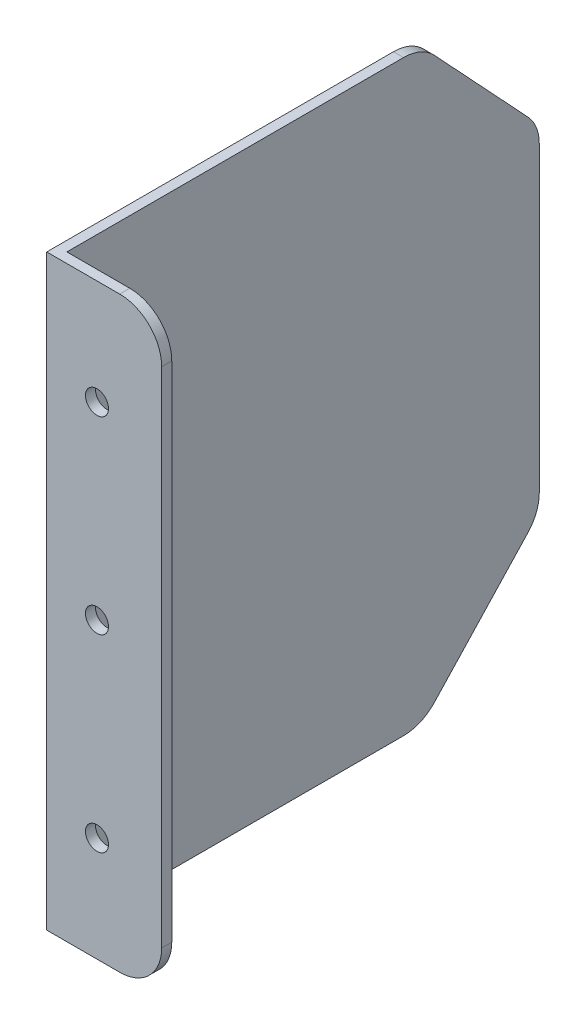
from build123d import *

# Parameters (mm, degrees)
SKETCH1_W           = 115
SKETCH1_H           = 140
BOSS_EXTRUDE1_DEPTH = 2.4
CUT_EXTRUDE1_DEPTH  = 3.4
FILLET1_R           = 10
SKETCH3_W           = 2.4
SKETCH3_H           = 140
BOSS_EXTRUDE2_DEPTH = 25
FILLET2_R           = 10
SKETCH4_R           = 2.75
CUT_EXTRUDE2_DEPTH  = 116


with BuildPart() as part:
    # Sketch1 → Boss-Extrude1 (new body)
    with BuildSketch(Plane(origin=(0, 0, 0), x_dir=(0, 0, -1), z_dir=(1, 0, 0))):
        with Locations((57.5, -70)):
            Rectangle(SKETCH1_W, SKETCH1_H)
    extrude(amount=BOSS_EXTRUDE1_DEPTH)

    # Sketch2 → Cut-Extrude1 (cut, through all)
    with BuildSketch(Plane(origin=(2.4, 0, 0), x_dir=(0, 0, -1), z_dir=(1, 0, 0))):
        Polygon((87, 0), (115, -30), (142.616199658, -32.505405645), (142.616199658, 14.875556406), align=None)
        Polygon((115, -110), (87, -140), (87, -152.661109726), (136.310004643, -152.661109726), align=None)
    extrude(amount=-CUT_EXTRUDE1_DEPTH, mode=Mode.SUBTRACT)

    # Fillet1
    fillet1_edges = [part.edges().sort_by_distance(p)[0] for p in [
        (1.2, 0, -87),
        (1.2, -30, -115),
        (1.2, -110, -115),
        (1.2, -140, -87),
    ]]
    fillet(fillet1_edges, radius=FILLET1_R)

    # Sketch3 → Boss-Extrude2 (add)
    with BuildSketch(Plane(origin=(2.4, 0, 0), x_dir=(0, 0, -1), z_dir=(1, 0, 0))):
        with Locations((1.2, -70)):
            Rectangle(SKETCH3_W, SKETCH3_H)
    extrude(amount=BOSS_EXTRUDE2_DEPTH)

    # Fillet2
    fillet2_edges = [part.edges().sort_by_distance(p)[0] for p in [
        (27.4, -140, -1.2),
        (27.4, 0, -1.2),
    ]]
    fillet(fillet2_edges, radius=FILLET2_R)

    # Sketch4 → Cut-Extrude2 (cut, through all)
    with BuildSketch(Plane.XY):
        with Locations((11.974983581, -70)):
            Circle(SKETCH4_R)
        with Locations((11.974983581, -25)):
            Circle(SKETCH4_R)
        with Locations((11.974983581, -115)):
            Circle(SKETCH4_R)
    extrude(amount=-CUT_EXTRUDE2_DEPTH, mode=Mode.SUBTRACT)


solid = part.part
